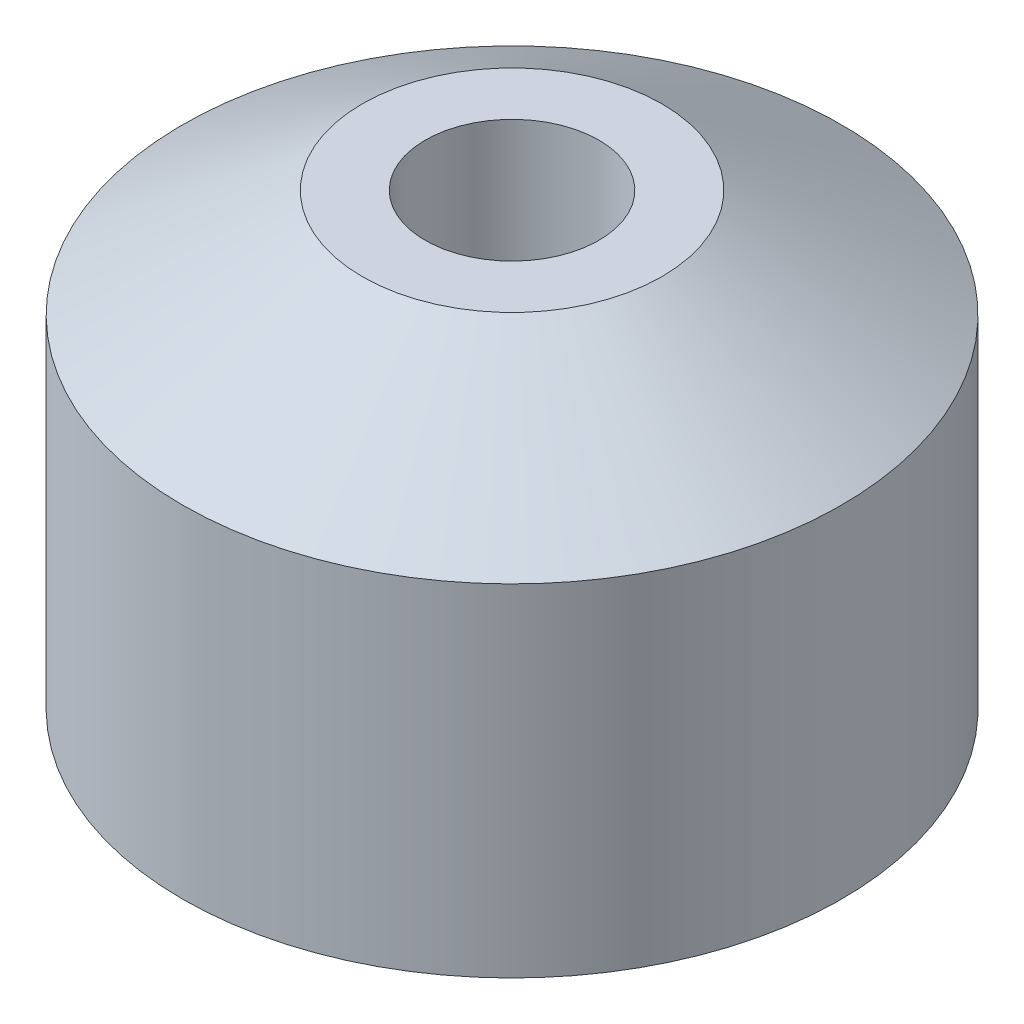
from build123d import *

# Parameters (mm, degrees)
CBORE_FOR_M2_5_SHCS1_D           = 2.9
CBORE_FOR_M2_5_SHCS1_CBORE_D     = 5.5
CBORE_FOR_M2_5_SHCS1_CBORE_DEPTH = 2.6


with BuildPart() as part:
    # Sketch1 → Revolve1 (revolve)
    with BuildSketch(Plane(origin=(0, 0, 0), x_dir=(0, 0, -1), z_dir=(1, 0, 0))):
        Polygon((-5.5, 5.697418143), (-5.5, 0), (0, 0), (0, 7.5), (-2.5, 7.5), align=None)
    revolve(axis=Axis((0, 7.5, 0), (0, -1, 0)))

    # CBORE for M2.5 SHCS1 (through all)
    with Locations(Plane(origin=(0, 0, 0), x_dir=(-1, 0, 0), z_dir=(0, -1, 0))):
        with Locations((0, 0)):
            CounterBoreHole(CBORE_FOR_M2_5_SHCS1_D / 2, CBORE_FOR_M2_5_SHCS1_CBORE_D / 2, CBORE_FOR_M2_5_SHCS1_CBORE_DEPTH)


solid = part.part
